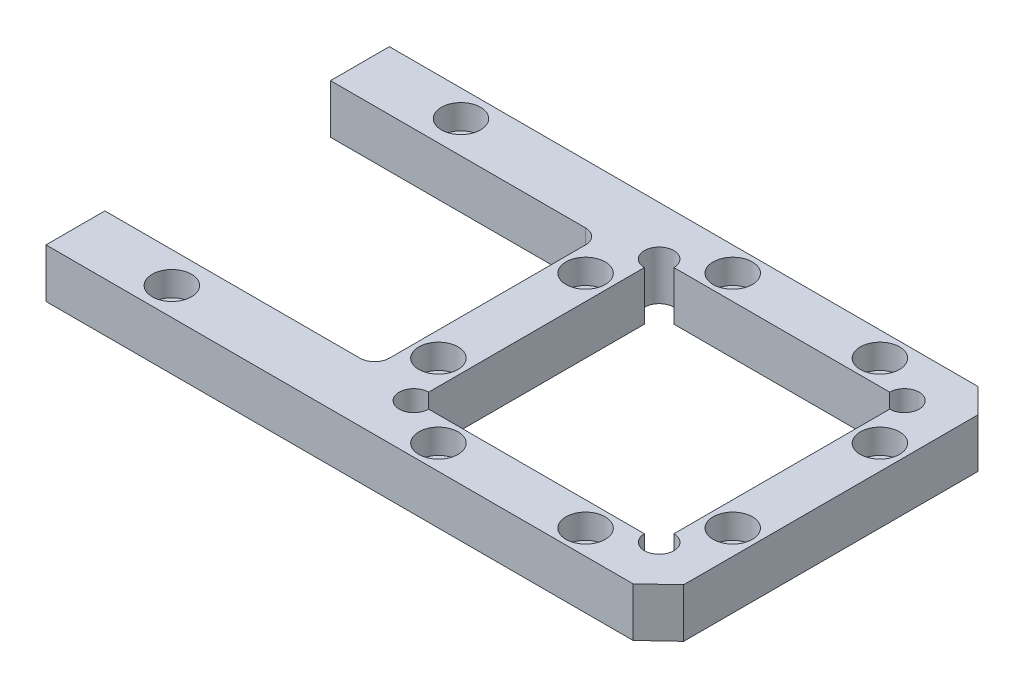
from build123d import *

# Parameters (mm, degrees)
BOSS_EXTRUDE1_DEPTH = 10
SKETCH4_W           = 55
SKETCH4_H           = 46
CUT_EXTRUDE1_DEPTH  = 11
SKETCH5_R           = 3
SKETCH5_W           = 50
SKETCH5_H           = 50
CUT_EXTRUDE2_DEPTH  = 11
SKETCH6_R           = 4
CUT_EXTRUDE4_DEPTH  = 5
SKETCH7_R           = 2.5
CUT_EXTRUDE5_DEPTH  = 6
FILLET1_R           = 3
SKETCH8_R           = 4
CUT_EXTRUDE6_DEPTH  = 5


with BuildPart() as part:
    # Sketch3 → Boss-Extrude1 (new body)
    with BuildSketch(Plane(origin=(0, 0, 0), x_dir=(1, 0, 0), z_dir=(0, 1, 0))):
        Polygon((0, 0), (0, 70), (120, 70), (125, 65), (125, 5), (119.666666667, 0), align=None)
    extrude(amount=BOSS_EXTRUDE1_DEPTH)

    # Sketch4 → Cut-Extrude1 (cut, through all)
    with BuildSketch(Plane(origin=(0, 10, 0), x_dir=(1, 0, 0), z_dir=(0, 1, 0))):
        with Locations((27.5, 35)):
            Rectangle(SKETCH4_W, SKETCH4_H)
    extrude(amount=-CUT_EXTRUDE1_DEPTH, mode=Mode.SUBTRACT)

    # Sketch5 → Cut-Extrude2 (cut, through all)
    with BuildSketch(Plane(origin=(0, 10, 0), x_dir=(1, 0, 0), z_dir=(0, 1, 0))):
        with Locations((65, 60)):
            Circle(SKETCH5_R)
        with Locations((65, 10)):
            Circle(SKETCH5_R)
        with Locations((115, 10)):
            Circle(SKETCH5_R)
        with Locations((115, 60)):
            Circle(SKETCH5_R)
        with Locations((90, 35)):
            Rectangle(SKETCH5_W, SKETCH5_H)
        with BuildLine():
            Line((65, 57), (65, 60))
            Line((65, 60), (68, 60))
            ThreePointArc((68, 60), (62.878679656, 62.121320344), (65, 57))
        make_face()
        with BuildLine():
            Line((68, 60), (65, 60))
            Line((65, 60), (65, 57))
            ThreePointArc((65, 57), (67.121320344, 57.878679656), (68, 60))
        make_face()
        with BuildLine():
            ThreePointArc((118, 60), (115, 63), (112, 60))
            Line((112, 60), (115, 60))
            Line((115, 60), (115, 57))
            ThreePointArc((115, 57), (117.121320344, 57.878679656), (118, 60))
        make_face()
        with BuildLine():
            Line((115, 60), (112, 60))
            ThreePointArc((112, 60), (112.878679656, 57.878679656), (115, 57))
            Line((115, 57), (115, 60))
        make_face()
        with BuildLine():
            ThreePointArc((118, 10), (117.121320344, 12.121320344), (115, 13))
            Line((115, 13), (115, 10))
            Line((115, 10), (112, 10))
            ThreePointArc((112, 10), (115, 7), (118, 10))
        make_face()
        with BuildLine():
            Line((115, 10), (115, 13))
            ThreePointArc((115, 13), (112.878679656, 12.121320344), (112, 10))
            Line((112, 10), (115, 10))
        make_face()
        with BuildLine():
            ThreePointArc((68, 10), (67.121320344, 12.121320344), (65, 13))
            Line((65, 13), (65, 10))
            Line((65, 10), (68, 10))
        make_face()
        with BuildLine():
            Line((65, 10), (65, 13))
            ThreePointArc((65, 13), (62.878679656, 7.878679656), (68, 10))
            Line((68, 10), (65, 10))
        make_face()
    extrude(amount=-CUT_EXTRUDE2_DEPTH, mode=Mode.SUBTRACT)

    # Sketch6 → Cut-Extrude4 (cut)
    with BuildSketch(Plane(origin=(0, 10, 0), x_dir=(1, 0, 0), z_dir=(0, 1, 0))):
        with Locations((20, 64.59775654)):
            Circle(SKETCH6_R)
        with Locations((20, 5.658501093)):
            Circle(SKETCH6_R)
    extrude(amount=-CUT_EXTRUDE4_DEPTH, mode=Mode.SUBTRACT)

    # Sketch7 → Cut-Extrude5 (cut, through all)
    with BuildSketch(Plane(origin=(0, 5, 0), x_dir=(1, 0, 0), z_dir=(0, 1, 0))):
        with Locations((20, 64.59775654)):
            Circle(SKETCH7_R)
        with Locations((20, 5.658501093)):
            Circle(SKETCH7_R)
    extrude(amount=-CUT_EXTRUDE5_DEPTH, mode=Mode.SUBTRACT)

    # Fillet1
    fillet1_edges = [part.edges().sort_by_distance(p)[0] for p in [
        (55, 5, -58),
        (55, 5, -12),
    ]]
    fillet(fillet1_edges, radius=FILLET1_R)

    # Sketch8 → Cut-Extrude6 (cut)
    with BuildSketch(Plane(origin=(0, 10, 0), x_dir=(1, 0, 0), z_dir=(0, 1, 0))):
        with Locations((120, 50)):
            Circle(SKETCH8_R)
        with Locations((120, 20)):
            Circle(SKETCH8_R)
        with Locations((105, 65)):
            Circle(SKETCH8_R)
        with Locations((75, 65)):
            Circle(SKETCH8_R)
        with Locations((75, 5)):
            Circle(SKETCH8_R)
        with Locations((105, 5)):
            Circle(SKETCH8_R)
        with Locations((60, 50)):
            Circle(SKETCH8_R)
        with Locations((60, 20)):
            Circle(SKETCH8_R)
    extrude(amount=-CUT_EXTRUDE6_DEPTH, mode=Mode.SUBTRACT)


solid = part.part
